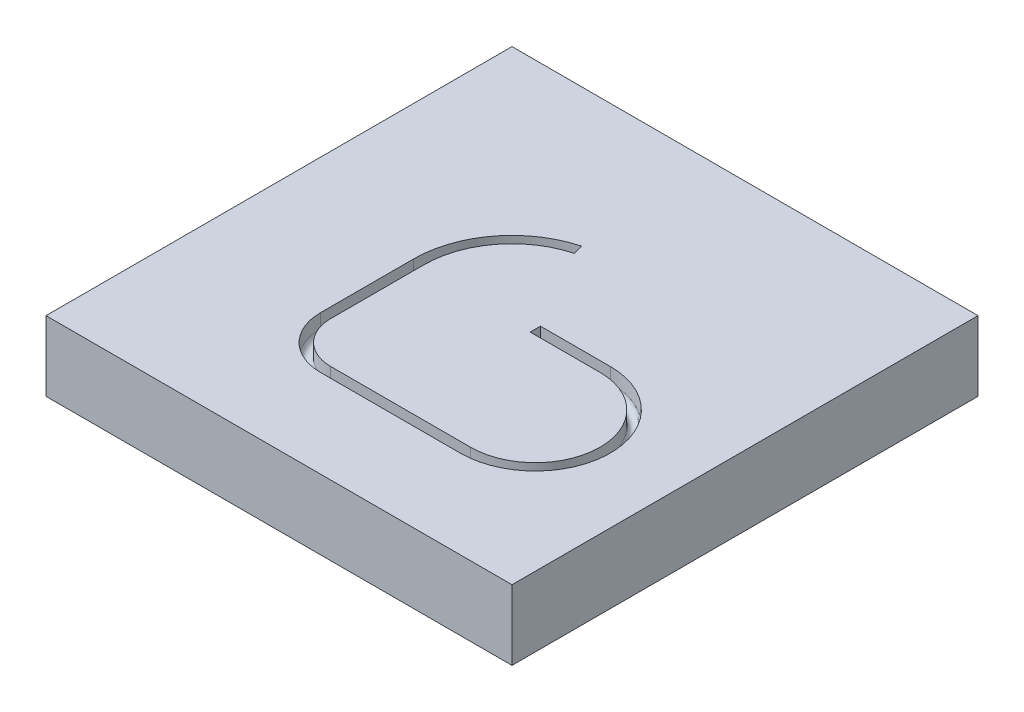
from build123d import *

# Parameters (mm, degrees)
AUFSATZ_LINEAR_START            = 3
SKIZZE4_W                       = 100
SKIZZE4_H                       = 100
AUFSATZ_LINEAR_AUSTRAGEN1_DEPTH = 15


with BuildPart() as part:
    # Skizze4 → Aufsatz-Linear austragen1 (new body)
    with BuildSketch(Plane(origin=(0, 0, 0), x_dir=(1, 0, 0), z_dir=(0, 1, 0)).offset(AUFSATZ_LINEAR_START)):
        Rectangle(SKIZZE4_W, SKIZZE4_H)
    extrude(amount=-AUFSATZ_LINEAR_AUSTRAGEN1_DEPTH)

    # Schnitt-Austragung1: sweep along a path in Skizze1_2
    with BuildLine(Plane(origin=(0, 0, 0), x_dir=(1, 0, 0), z_dir=(0, 1, 0))) as schnitt_austragung1_path:
        Line((5, 0), (20, 0))
        ThreePointArc((20, 0), (35, -15), (20, -30))
        Line((20, -30), (-10, -30))
        ThreePointArc((-10, -30), (-17.071067812, -27.071067812), (-20, -20))
        Line((-20, -20), (-20, 0))
        ThreePointArc((-20, 0), (-15.867066806, 12.17522858), (-5.176380902, 19.318516526))
    # Skizze5 → Schnitt-Austragung1 (sweep, cut)
    with BuildSketch(Plane(origin=(0, 0, 0), x_dir=(-0.258819045, 0, -0.965925826), z_dir=(0.965925826, 0, -0.258819045))):
        with BuildLine():
            Line((21.1, 0), (21.1, 3))
            Line((21.1, 3), (18.9, 3))
            Line((18.9, 3), (18.9, 0))
            ThreePointArc((18.9, 0), (20, -1.1), (21.1, 0))
        make_face()
    sweep(path=schnitt_austragung1_path.line, mode=Mode.SUBTRACT)


solid = part.part
